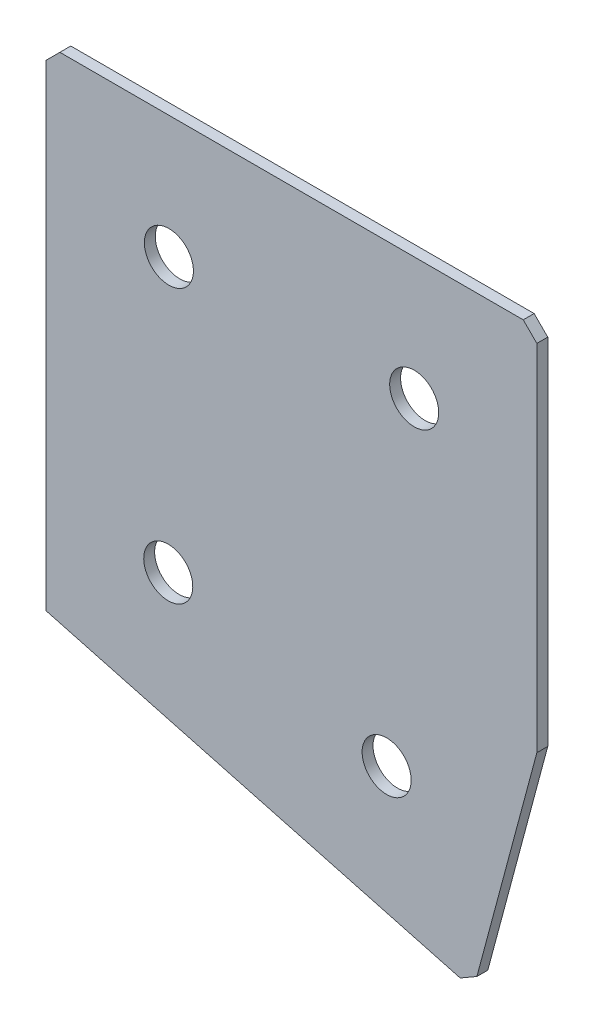
from build123d import *

# Parameters (mm, degrees)
EXTRUDE_1_DEPTH   = 2
HOLE_WIZARD_M81_D = 9
CHAMFER_1_SIZE    = 2.5


with BuildPart() as part:
    # Эскиз3 → Бобышка-Вытянуть1 (new body)
    with BuildSketch(Plane(origin=(0, 0, 0), x_dir=(1, 0, 0), z_dir=(0, 0, -1))):
        Polygon((0, 0), (90, 0), (90, 67.5279992), (78.35314297, 110.994661383), (0, 90), align=None)
    extrude(amount=EXTRUDE_1_DEPTH)

    # Отверстие с зазором M81 (through all)
    with Locations(Plane(origin=(0, 0, -2), x_dir=(1, 0, 0), z_dir=(0, 0, -1))):
        with Locations((67.5, 22.5), (22.380378704, 72.703090341), (62.443240394, 83.437901777), (22.5, 22.5)):
            Hole(HOLE_WIZARD_M81_D / 2)

    # Фаска1
    chamfer_1_edges = [part.edges().sort_by_distance(p)[0] for p in [
        (78.35314297, -110.994661383, -1),
        (90, 0, -1),
        (0, 0, -1),
    ]]
    chamfer(chamfer_1_edges, length=CHAMFER_1_SIZE)


solid = part.part
